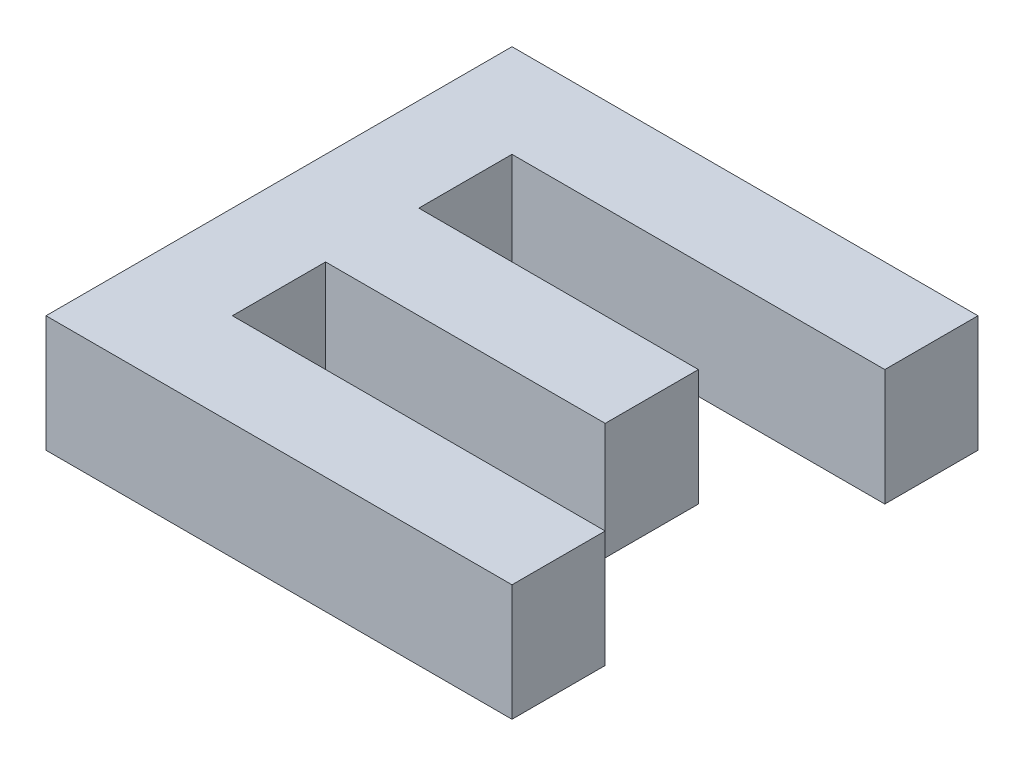
from build123d import *

# Parameters (mm, degrees)
BOSS_EXTRUDE1_DEPTH = 10


with BuildPart() as part:
    # Sketch1 → Boss-Extrude1 (new body)
    with BuildSketch(Plane(origin=(0, 0, 0), x_dir=(1, 0, 0), z_dir=(0, 1, 0))):
        Polygon((200, 0), (240, 0), (240, 8), (208, 8), (208, 16), (232, 16), (232, 24), (208, 24), (208, 32), (240, 32), (240, 40), (200, 40), align=None)
    extrude(amount=BOSS_EXTRUDE1_DEPTH)


solid = part.part
